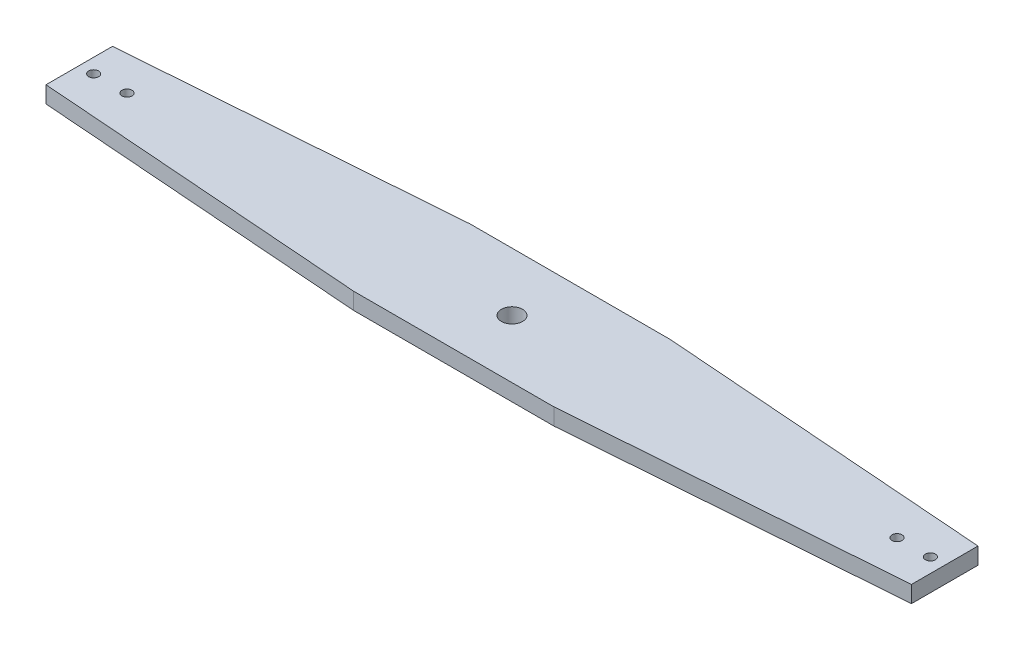
from build123d import *

# Parameters (mm, degrees)
SKETCH1_R           = 3
SKETCH1_R_2         = 6.35
BOSS_EXTRUDE1_DEPTH = 10


with BuildPart() as part:
    # Sketch1 → Boss-Extrude1 (new body)
    with BuildSketch(Plane(origin=(0, 0, 0), x_dir=(1, 0, 0), z_dir=(0, 1, 0))):
        Polygon((-60, 34.925), (60, 34.925), (259.43812075, 19.943812075), (259.43812075, -19.943812075), (60, -34.925), (-60, -34.925), (-259.43812075, -19.943812075), (-259.43812075, 19.943812075), align=None)
        with Locations((-250.825, 0)):
            Circle(SKETCH1_R, mode=Mode.SUBTRACT)
        with Locations((250.825, 0)):
            Circle(SKETCH1_R, mode=Mode.SUBTRACT)
        Circle(SKETCH1_R_2, mode=Mode.SUBTRACT)
        with Locations((-230.825, 0)):
            Circle(SKETCH1_R, mode=Mode.SUBTRACT)
        with Locations((230.825, 0)):
            Circle(SKETCH1_R, mode=Mode.SUBTRACT)
    extrude(amount=BOSS_EXTRUDE1_DEPTH)


solid = part.part
